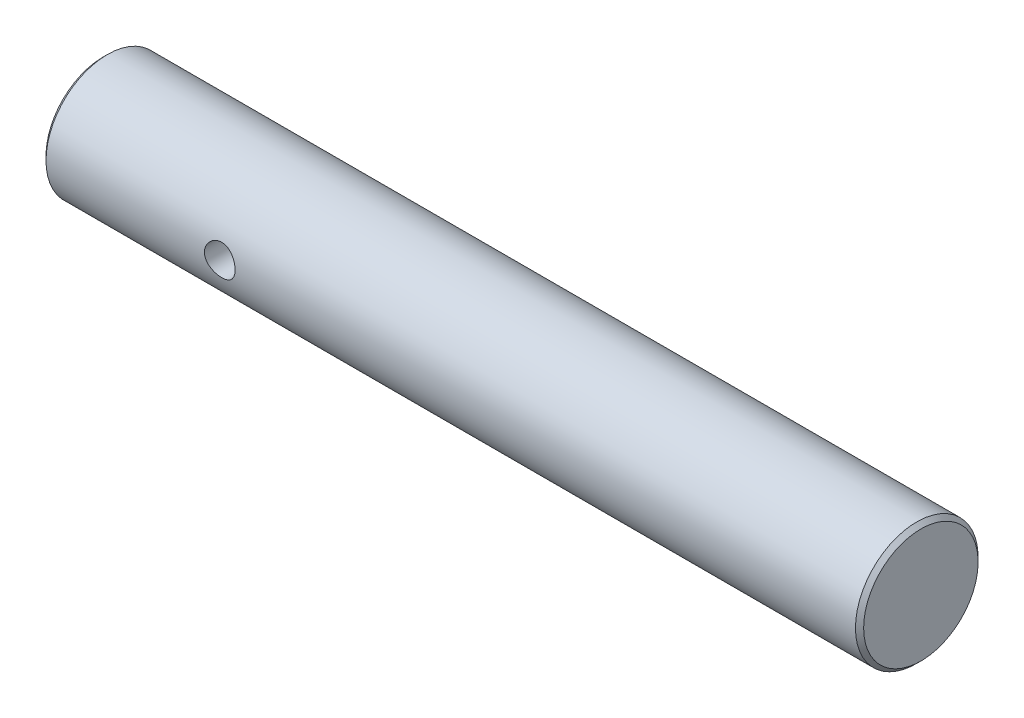
from build123d import *

# Parameters (mm, degrees)
ESQUISSE1_W                  = 40
ESQUISSE1_H                  = 3
CHANFREIN1_SIZE              = 0.2
ESQUISSE2_R                  = 0.75
ENL_V_MAT_EXTRU_1_DEPTH      = 4
ENL_V_MAT_EXTRU_1_DEPTH_BACK = 4


with BuildPart() as part:
    # Esquisse1 → Révolution1 (revolve)
    with BuildSketch(Plane.XY):
        with Locations((5, 1.5)):
            Rectangle(ESQUISSE1_W, ESQUISSE1_H)
    revolve(axis=Axis((-15, 0, 0), (1, 0, 0)))

    # Chanfrein1
    chanfrein1_edges = [part.edges().sort_by_distance(p)[0] for p in [
        (-15, -3, 0),
        (25, -3, 0),
    ]]
    chamfer(chanfrein1_edges, length=CHANFREIN1_SIZE)

    # Esquisse2 → Enlèv. mat.-Extru.1 (cut, two sides)
    with BuildSketch(Plane.XY) as enl_v_mat_extru_1_sk:
        with Locations((-6.3, 0)):
            Circle(ESQUISSE2_R)
    extrude(amount=ENL_V_MAT_EXTRU_1_DEPTH, mode=Mode.SUBTRACT)
    extrude(enl_v_mat_extru_1_sk.sketch, amount=-ENL_V_MAT_EXTRU_1_DEPTH_BACK, mode=Mode.SUBTRACT)


solid = part.part
